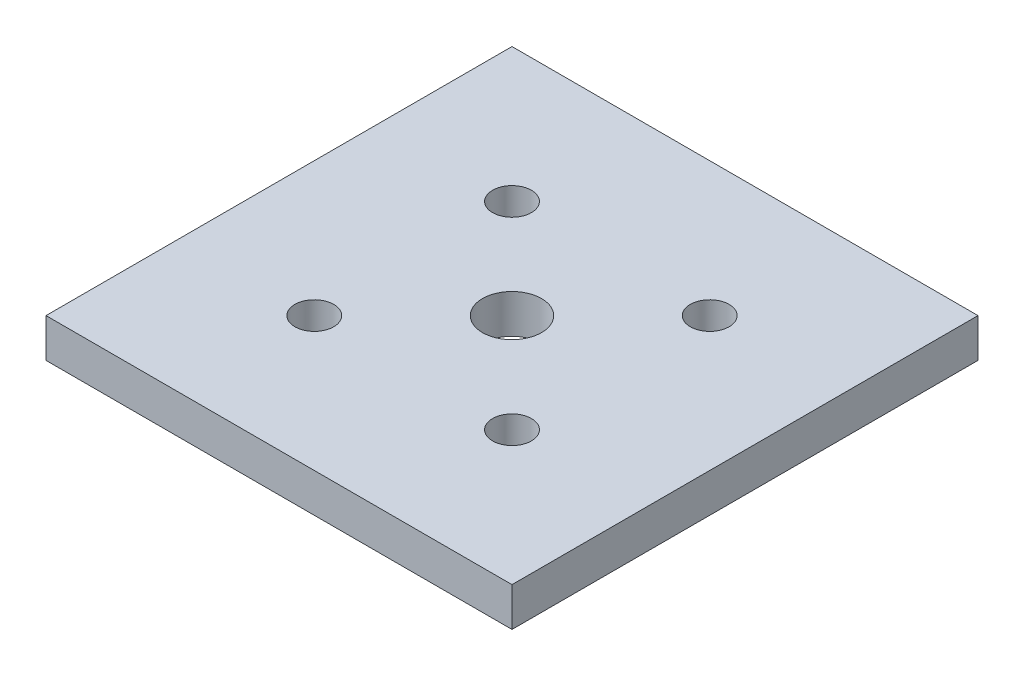
from build123d import *

# Parameters (mm, degrees)
SKETCH1_W           = 60
SKETCH1_H           = 60
SKETCH1_R           = 3.8
SKETCH1_R_2         = 2.5
BOSS_EXTRUDE1_DEPTH = 5


with BuildPart() as part:
    # Sketch1 → Boss-Extrude1 (new body)
    with BuildSketch(Plane(origin=(0, 0, 0), x_dir=(1, 0, 0), z_dir=(0, 1, 0))):
        Rectangle(SKETCH1_W, SKETCH1_H)
        Circle(SKETCH1_R, mode=Mode.SUBTRACT)
        with Locations((-12.727922061, 12.727922061)):
            Circle(SKETCH1_R_2, mode=Mode.SUBTRACT)
        with Locations((12.727922061, 12.727922061)):
            Circle(SKETCH1_R_2, mode=Mode.SUBTRACT)
        with Locations((12.727922061, -12.727922061)):
            Circle(SKETCH1_R_2, mode=Mode.SUBTRACT)
        with Locations((-12.727922061, -12.727922061)):
            Circle(SKETCH1_R_2, mode=Mode.SUBTRACT)
    extrude(amount=BOSS_EXTRUDE1_DEPTH)


solid = part.part
